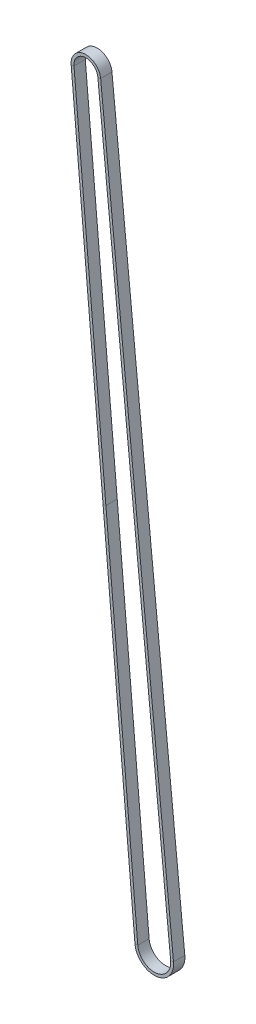
from build123d import *

# Parameters (mm, degrees)
SKETCH2_W = 1.5
SKETCH2_H = 6


with BuildPart() as part:
    # Sweep1: sweep along a path in Sketch1
    with BuildLine(Plane.XY) as sweep1_path:
        Line((-42.529783528, 385.761299265), (-8.716710227, -0.762537091))
        ThreePointArc((-8.716710227, -0.762537091), (0.816439268, -8.711826842), (8.706610141, 0.870310207))
        Line((8.706610141, 0.870310207), (-29.885431032, 386.946279875))
        ThreePointArc((-29.885431032, 386.946279875), (-36.796444032, 392.636980519), (-42.529783528, 385.761299265))
    # Sketch2 → Sweep1 (sweep)
    with BuildSketch(Plane(origin=(-25.623246878, 192.499381087, 0), x_dir=(-0.996195455, -0.087147096, 0), z_dir=(0.087147096, -0.996195455, 0))):
        with Locations((0.75, 0)):
            Rectangle(SKETCH2_W, SKETCH2_H)
    sweep(path=sweep1_path.line)


solid = part.part
